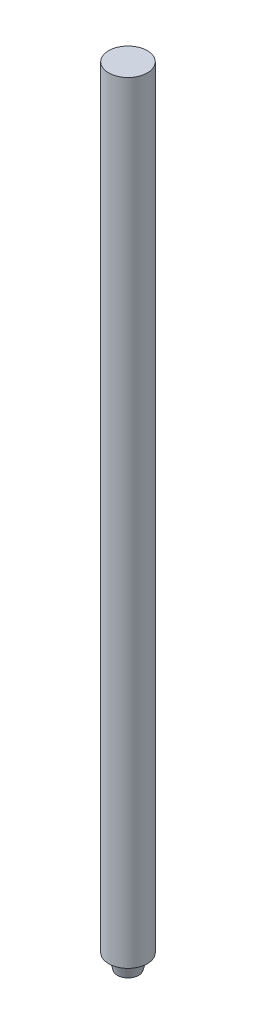
from build123d import *

# Parameters (mm, degrees)
ESBO_O1_R       = 4
EXTRUS_O1_DEPTH = 159.86
ESBO_O3_R       = 3
EXTRUS_O2_DEPTH = 3
EXTRUS_O2_TAPER = 15


with BuildPart() as part:
    # Esboço1 → Extrusão1 (new body)
    with BuildSketch(Plane(origin=(0, 0, 0), x_dir=(1, 0, 0), z_dir=(0, 1, 0))):
        with Locations(Location((0, 0, 0), (0, 0, 270))):  # turned: the seam where the file's is
            Circle(ESBO_O1_R)
    extrude(amount=-EXTRUS_O1_DEPTH)

    # Esboço3 → Extrusão2 (add)
    with BuildSketch(Plane.XZ.offset(159.86)):
        Circle(ESBO_O3_R)
    extrude(amount=EXTRUS_O2_DEPTH, taper=EXTRUS_O2_TAPER)


solid = part.part
